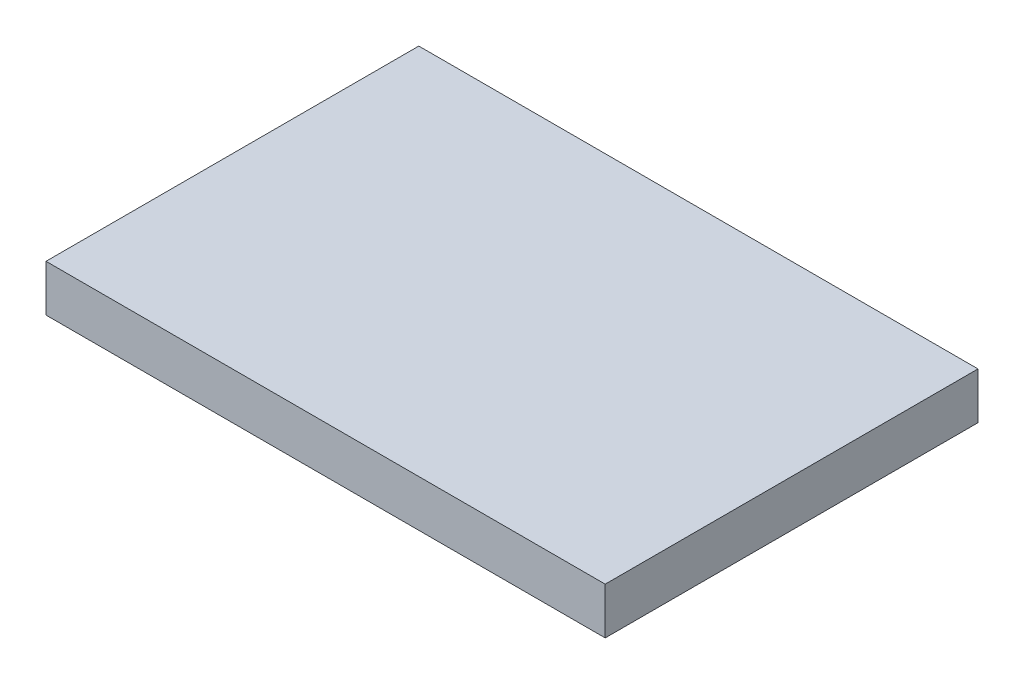
from build123d import *

# Parameters (mm, degrees)
SKETCH1_W           = 120
SKETCH1_H           = 80
BOSS_EXTRUDE1_DEPTH = 10


with BuildPart() as part:
    # Sketch1 → Boss-Extrude1 (new body)
    with BuildSketch(Plane.XZ.offset(-340)):
        with Locations((-26.489460092, -13.07873573)):
            Rectangle(SKETCH1_W, SKETCH1_H)
    extrude(amount=BOSS_EXTRUDE1_DEPTH)


solid = part.part
